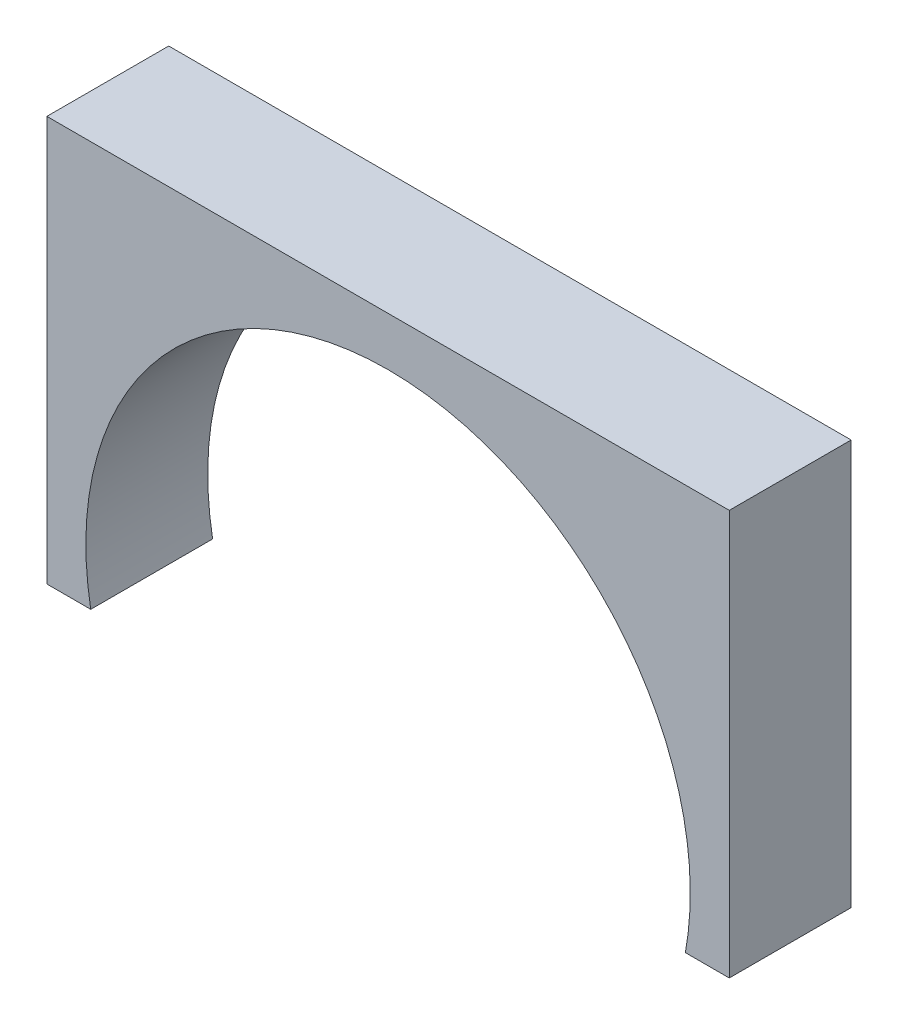
from build123d import *

# Parameters (mm, degrees)
BOSS_EXTRUDE1_DEPTH = 25


with BuildPart() as part:
    # Sketch1 → Boss-Extrude1 (new body)
    with BuildSketch(Plane.XY):
        with BuildLine():
            Line((-70, 72), (-70, -11.090536506))
            Line((-70, -11.090536506), (-61, -11.090536506))
            ThreePointArc((-61, -11.090536506), (0, 62), (61, -11.090536506))
            Line((61, -11.090536506), (70, -11.090536506))
            Line((70, -11.090536506), (70, 72))
            Line((70, 72), (-70, 72))
        make_face()
    extrude(amount=BOSS_EXTRUDE1_DEPTH)


solid = part.part
